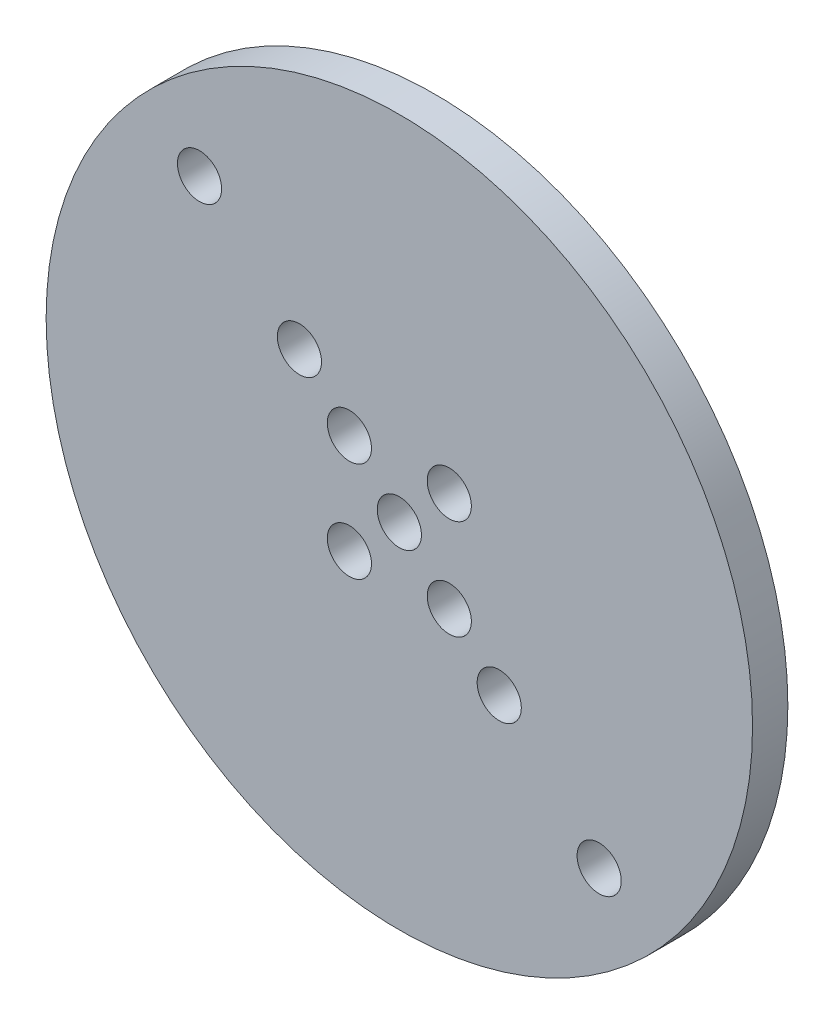
from build123d import *

# Parameters (mm, degrees)
SKETCH1_R           = 63.5
BOSS_EXTRUDE1_DEPTH = 6.35
SKETCH2_R           = 3.96875
CUT_EXTRUDE1_DEPTH  = 7.35


with BuildPart() as part:
    # Sketch1 → Boss-Extrude1 (new body)
    with BuildSketch(Plane.XY):
        Circle(SKETCH1_R)
    extrude(amount=BOSS_EXTRUDE1_DEPTH)

    # Sketch2 → Cut-Extrude1 (cut, through all)
    with BuildSketch(Plane.XY.offset(6.35)):
        Circle(SKETCH2_R)
        with Locations((-8.980256121, 8.980256121)):
            Circle(SKETCH2_R)
        with Locations((8.980256121, -8.980256121)):
            Circle(SKETCH2_R)
        with Locations((8.980256121, 8.980256121)):
            Circle(SKETCH2_R)
        with Locations((-8.980256121, -8.980256121)):
            Circle(SKETCH2_R)
        with Locations((17.960512242, -17.960512242)):
            Circle(SKETCH2_R)
        with Locations((35.921024484, -35.921024484)):
            Circle(SKETCH2_R)
        with Locations((-17.960512242, 17.960512242)):
            Circle(SKETCH2_R)
        with Locations((-35.921024484, 35.921024484)):
            Circle(SKETCH2_R)
    extrude(amount=-CUT_EXTRUDE1_DEPTH, mode=Mode.SUBTRACT)


solid = part.part
